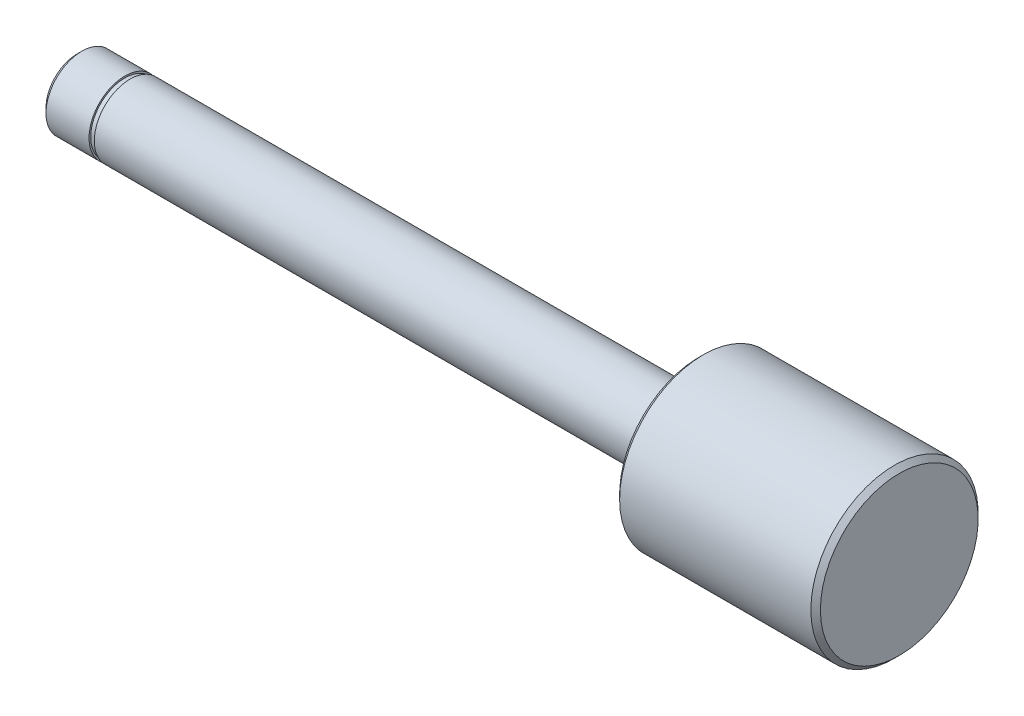
from build123d import *

# Parameters (mm, degrees)
CHANFREIN1_SIZE = 1
ESQUISSE2_W     = 1.1
ESQUISSE2_H     = 8.504088504


with BuildPart() as part:
    # Esquisse1 → Révolution1 (revolve)
    with BuildSketch(Plane.XY, mode=Mode.PRIVATE) as r_volution1_sk:
        Polygon((-86, 0), (-86, 7.5), (44, 7.5), (44, 17.5), (86, 17.5), (86, 0), align=None)
    revolve(r_volution1_sk.sketch.rotate(Axis((-86, 0, 0), (1, 0, 0)), 90), axis=Axis((-86, 0, 0), (1, 0, 0)))  # turned: the seam where the file's is

    # Chanfrein1
    chanfrein1_edges = [part.edges().sort_by_distance(p)[0] for p in [
        (86, 0, -17.5),
        (44, 0, -17.5),
        (-86, 0, -7.5),
    ]]
    chamfer(chanfrein1_edges, length=CHANFREIN1_SIZE)

    # Esquisse2 → Enlèvement de matière-Révolution1 (revolve, cut)
    with BuildSketch(Plane.XY, mode=Mode.PRIVATE) as enl_vement_de_mati_re_r_volution1_sk:
        with Locations((-75.45, 11.402044252)):
            Rectangle(ESQUISSE2_W, ESQUISSE2_H)
    revolve(enl_vement_de_mati_re_r_volution1_sk.sketch.rotate(Axis((0, 0, 0), (-1, 0, 0)), 270), axis=Axis((0, 0, 0), (-1, 0, 0)), mode=Mode.SUBTRACT)  # turned: the seam where the file's is


solid = part.part
